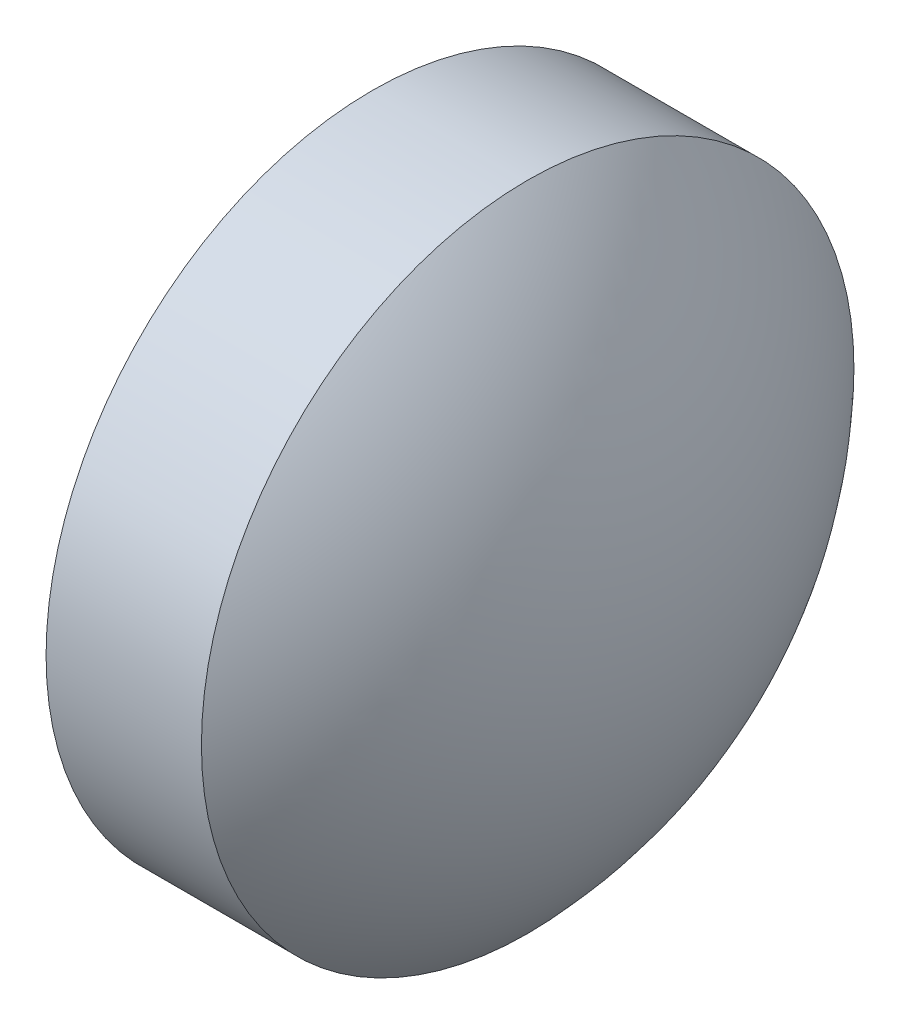
from build123d import *


with BuildPart() as part:
    # 草图1 → 旋转1 (revolve)
    with BuildSketch(Plane.XY):
        with BuildLine():
            Line((390.958546637, 105.876474886), (390.958546637, 109.026474886))
            Line((390.958546637, 109.026474886), (392.458546637, 109.026474886))
            ThreePointArc((392.458546637, 109.026474886), (393.384626964, 107.570951207), (393.708546637, 105.876474886))
            Line((393.708546637, 105.876474886), (390.958546637, 105.876474886))
        make_face()
    revolve(axis=Axis((390.097908549, 105.876474886, 0), (1, 0, 0)))


solid = part.part
